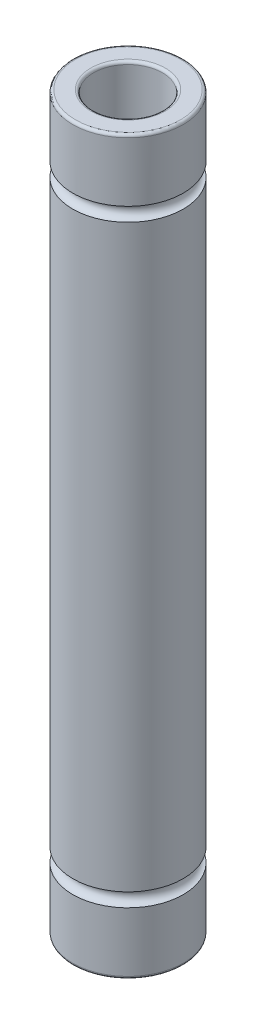
from build123d import *

# Parameters (mm, degrees)
SKETCH1_R           = 4
SKETCH1_R_2         = 2.5
BOSS_EXTRUDE1_DEPTH = 26.5
SKETCH2_R           = 0.5
FILLET1_R           = 0.2


with BuildPart() as part:
    # Sketch1 → Boss-Extrude1 (new body, symmetric)
    with BuildSketch(Plane(origin=(0, 0, 0), x_dir=(1, 0, 0), z_dir=(0, 1, 0))):
        Circle(SKETCH1_R)
        Circle(SKETCH1_R_2, mode=Mode.SUBTRACT)
    extrude(amount=BOSS_EXTRUDE1_DEPTH, both=True)

    # Sketch2 → Cut-Revolve1 (revolve, cut)
    with BuildSketch(Plane.XY):
        with Locations((4, -21.5)):
            Circle(SKETCH2_R)
    cut_revolve1 = revolve(axis=Axis((0, 35.374478172, 0), (0, -1, 0)), mode=Mode.SUBTRACT)

    # Mirror1: Cut-Revolve1 across plane
    add(cut_revolve1.mirror(Plane.ZX), mode=Mode.SUBTRACT)

    # Fillet1
    fillet1_edges = [part.edges().sort_by_distance(p)[0] for p in [
        (-4, -26.5, 0),
        (-4, 26.5, 0),
        (-2.5, -26.5, 0),
        (-2.5, 26.5, 0),
    ]]
    fillet(fillet1_edges, radius=FILLET1_R)


solid = part.part
